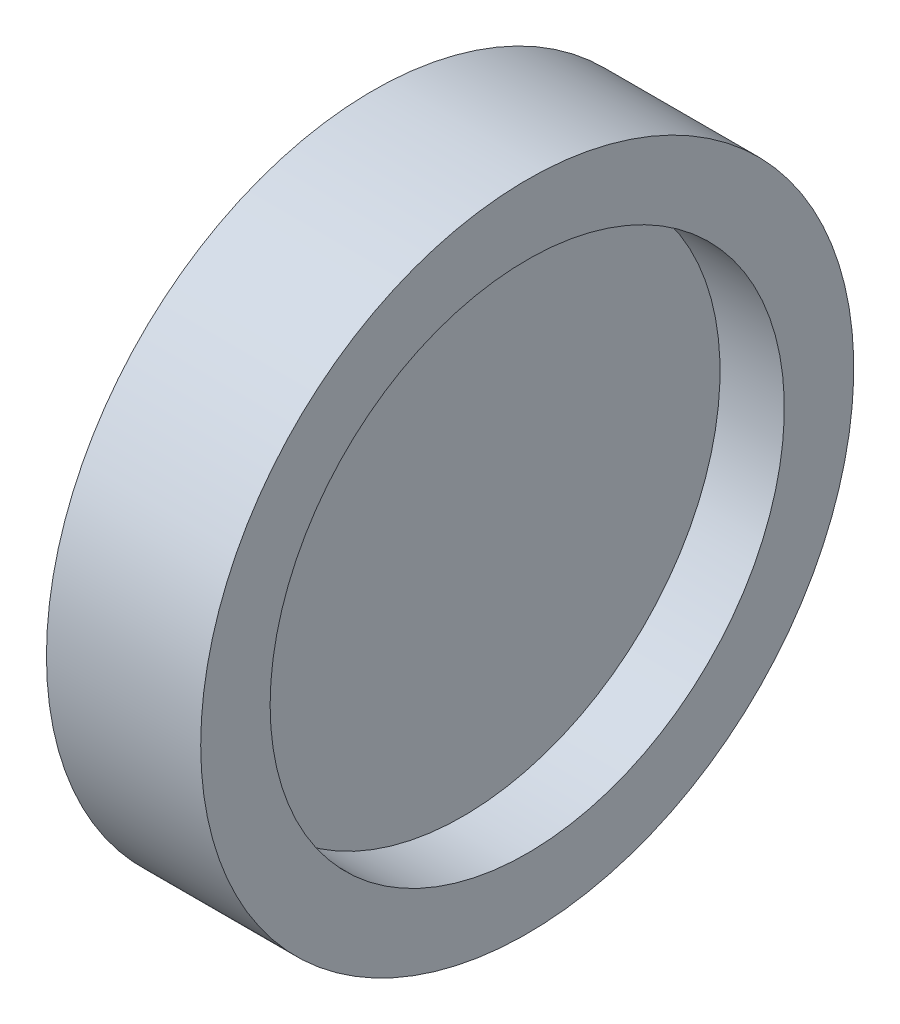
from build123d import *

# Parameters (mm, degrees)
SKETCH_1_W = 1
SKETCH_1_H = 10
SKETCH_4_W = 6
SKETCH_4_H = 2.7


with BuildPart() as part:
    # 草图1 → 旋转2 (revolve)
    with BuildSketch(Plane.XY, mode=Mode.PRIVATE) as revolve_2_sk:
        with Locations((0, 5)):
            Rectangle(SKETCH_1_W, SKETCH_1_H)
    revolve(revolve_2_sk.sketch.rotate(Axis((-0.5, 0, 0), (1, 0, 0)), 90), axis=Axis((-0.5, 0, 0), (1, 0, 0)))  # turned: the seam where the file's is

    # 草图4 → 旋转3 (revolve)
    with BuildSketch(Plane.XY, mode=Mode.PRIVATE) as revolve_3_sk:
        with Locations((0, 11.35)):
            Rectangle(SKETCH_4_W, SKETCH_4_H)
    revolve(revolve_3_sk.sketch.rotate(Axis((-1.614212419, 0, 0), (1, 0, 0)), 90), axis=Axis((-1.614212419, 0, 0), (1, 0, 0)))  # turned: the seam where the file's is


solid = part.part
